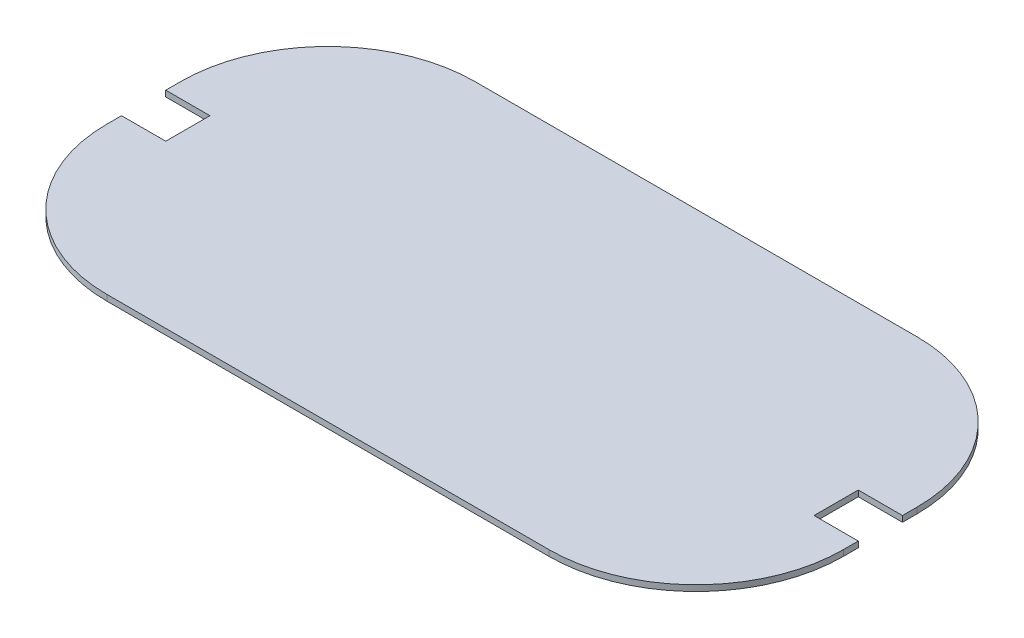
from build123d import *

# Parameters (mm, degrees)
SKETCH1_W           = 500
SKETCH1_H           = 250
BOSS_EXTRUDE1_DEPTH = 4
FILLET1_R           = 100
CUT_EXTRUDE1_DEPTH  = 10


with BuildPart() as part:
    # Sketch1 → Boss-Extrude1 (new body)
    with BuildSketch(Plane(origin=(0, 0, 0), x_dir=(1, 0, 0), z_dir=(0, 1, 0))):
        Rectangle(SKETCH1_W, SKETCH1_H)
    extrude(amount=BOSS_EXTRUDE1_DEPTH)

    # Fillet1
    fillet1_edges = [part.edges().sort_by_distance(p)[0] for p in [
        (250, 2, 125),
        (-250, 2, 125),
        (-250, 2, -125),
        (250, 2, -125),
    ]]
    fillet(fillet1_edges, radius=FILLET1_R)

    # Sketch2 → Cut-Extrude1 (cut)
    with BuildSketch(Plane(origin=(0, 0, 0), x_dir=(-1, 0, 0), z_dir=(0, -1, 0))):
        Polygon((250, 0), (250, -15), (220, -15), (220, 15), (250, 15), align=None)
        Polygon((-250, 0), (-250, -15), (-220, -15), (-220, 15), (-250, 15), align=None)
    extrude(amount=-CUT_EXTRUDE1_DEPTH, mode=Mode.SUBTRACT)


solid = part.part
